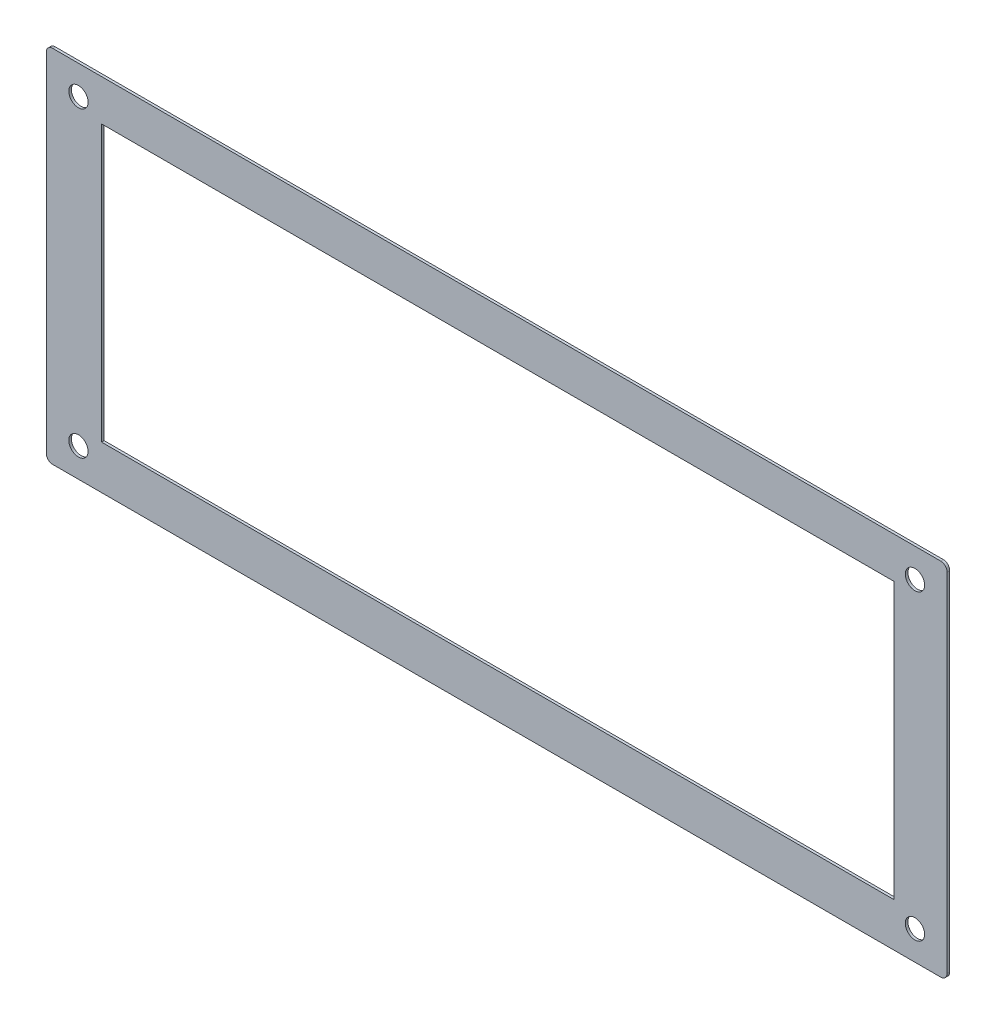
from build123d import *

# Parameters (mm, degrees)
SKETCH1_R           = 1.5
SKETCH1_W           = 123.128854939
SKETCH1_H           = 42.830428858
BOSS_EXTRUDE1_DEPTH = 0.4


with BuildPart() as part:
    # Sketch1 → Boss-Extrude1 (new body)
    with BuildSketch(Plane.XY):
        with BuildLine():
            Line((1, 0), (139, 0))
            ThreePointArc((139, 0), (139.707106781, 0.292893219), (140, 1))
            Line((140, 1), (140, 55))
            ThreePointArc((140, 55), (139.707106781, 55.707106781), (139, 56))
            Line((139, 56), (1, 56))
            ThreePointArc((1, 56), (0.292893219, 55.707106781), (0, 55))
            Line((0, 55), (0, 1))
            ThreePointArc((0, 1), (0.292893219, 0.292893219), (1, 0))
        make_face()
        with Locations((5, 51.5)):
            Circle(SKETCH1_R, mode=Mode.SUBTRACT)
        with Locations((5, 4.5)):
            Circle(SKETCH1_R, mode=Mode.SUBTRACT)
        with Locations((135, 4.5)):
            Circle(SKETCH1_R, mode=Mode.SUBTRACT)
        with Locations((135, 51.5)):
            Circle(SKETCH1_R, mode=Mode.SUBTRACT)
        with Locations((70.169366708, 28.217965612)):
            Rectangle(SKETCH1_W, SKETCH1_H, mode=Mode.SUBTRACT)
    extrude(amount=-BOSS_EXTRUDE1_DEPTH)


solid = part.part
